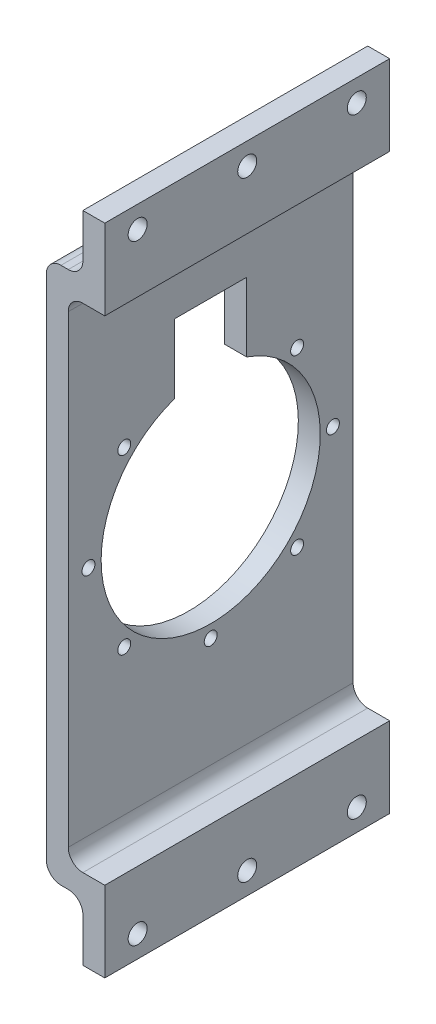
from build123d import *

# Parameters (mm, degrees)
BOSS_EXTRUDE1_DEPTH = 49.53
FILLET1_R           = 5.08
SKETCH7_R           = 2.2499955
SKETCH7_R_2         = 38.1
CUT_EXTRUDE1_DEPTH  = 26.67
CUT_EXTRUDE2_START  = -7.62
SKETCH8_R           = 3.302
CUT_EXTRUDE2_DEPTH  = 7.62
CUT_EXTRUDE3_DEPTH  = 7.62


with BuildPart() as part:
    # Sketch1 → Boss-Extrude1 (new body, symmetric)
    with BuildSketch(Plane.XY):
        Polygon((0, 0), (0, 171.45), (12.7, 171.45), (12.7, 179.07), (12.7, 199.39), (5.08, 199.39), (5.08, 179.07), (-7.62, 179.07), (-7.62, 171.45), (-7.62, -7.62), (5.08, -7.62), (5.08, -27.94), (12.7, -27.94), (12.7, -7.62), (12.7, 0), align=None)
    extrude(amount=BOSS_EXTRUDE1_DEPTH, both=True)

    # Fillet1
    fillet1_edges = [part.edges().sort_by_distance(p)[0] for p in [
        (5.08, -7.62, 0),
        (-7.62, -7.62, 0),
        (-7.62, 179.07, 0),
        (5.08, 179.07, 0),
        (0, 171.45, 0),
        (0, 0, 0),
    ]]
    fillet(fillet1_edges, radius=FILLET1_R)

    # Sketch7 → Cut-Extrude1 (cut)
    with BuildSketch(Plane(origin=(0, 0, 0), x_dir=(0, 0, -1), z_dir=(1, 0, 0))):
        with Locations((-42.5, 85.725)):
            Circle(SKETCH7_R)
        with Locations((-30.0520382, 115.7770382)):
            Circle(SKETCH7_R)
        with Locations((0, 128.225)):
            Circle(SKETCH7_R)
        with Locations((30.0520382, 115.7770382)):
            Circle(SKETCH7_R)
        with Locations((42.5, 85.725)):
            Circle(SKETCH7_R)
        with Locations((30.0520382, 55.6729618)):
            Circle(SKETCH7_R)
        with Locations((0, 43.225)):
            Circle(SKETCH7_R)
        with Locations((-30.0520382, 55.6729618)):
            Circle(SKETCH7_R)
        with Locations((0, 85.725)):
            Circle(SKETCH7_R_2)
    extrude(amount=-CUT_EXTRUDE1_DEPTH, mode=Mode.SUBTRACT)

    # Sketch8 → Cut-Extrude2 (cut)
    with BuildSketch(Plane.ZY.offset(-5.08).offset(CUT_EXTRUDE2_START)):
        with Locations((-38.1, 191.77)):
            Circle(SKETCH8_R)
        with Locations((0, 191.77)):
            Circle(SKETCH8_R)
        with Locations((38.1, 191.77)):
            Circle(SKETCH8_R)
    cut_extrude2 = extrude(amount=CUT_EXTRUDE2_DEPTH, mode=Mode.SUBTRACT)

    # Mirror1: Cut-Extrude2 across plane
    add(cut_extrude2.mirror(Plane.ZX.offset(85.725)), mode=Mode.SUBTRACT)

    # Sketch14 → Cut-Extrude3 (cut)
    with BuildSketch(Plane.ZY.offset(7.62)):
        with BuildLine():
            Line((12.5, 121.716110013), (12.5, 145.725))
            Line((12.5, 145.725), (-12.5, 145.725))
            Line((-12.5, 145.725), (-12.5, 121.716110013))
            ThreePointArc((-12.5, 121.716110013), (0, 123.825), (12.5, 121.716110013))
        make_face()
    extrude(amount=-CUT_EXTRUDE3_DEPTH, mode=Mode.SUBTRACT)


solid = part.part
